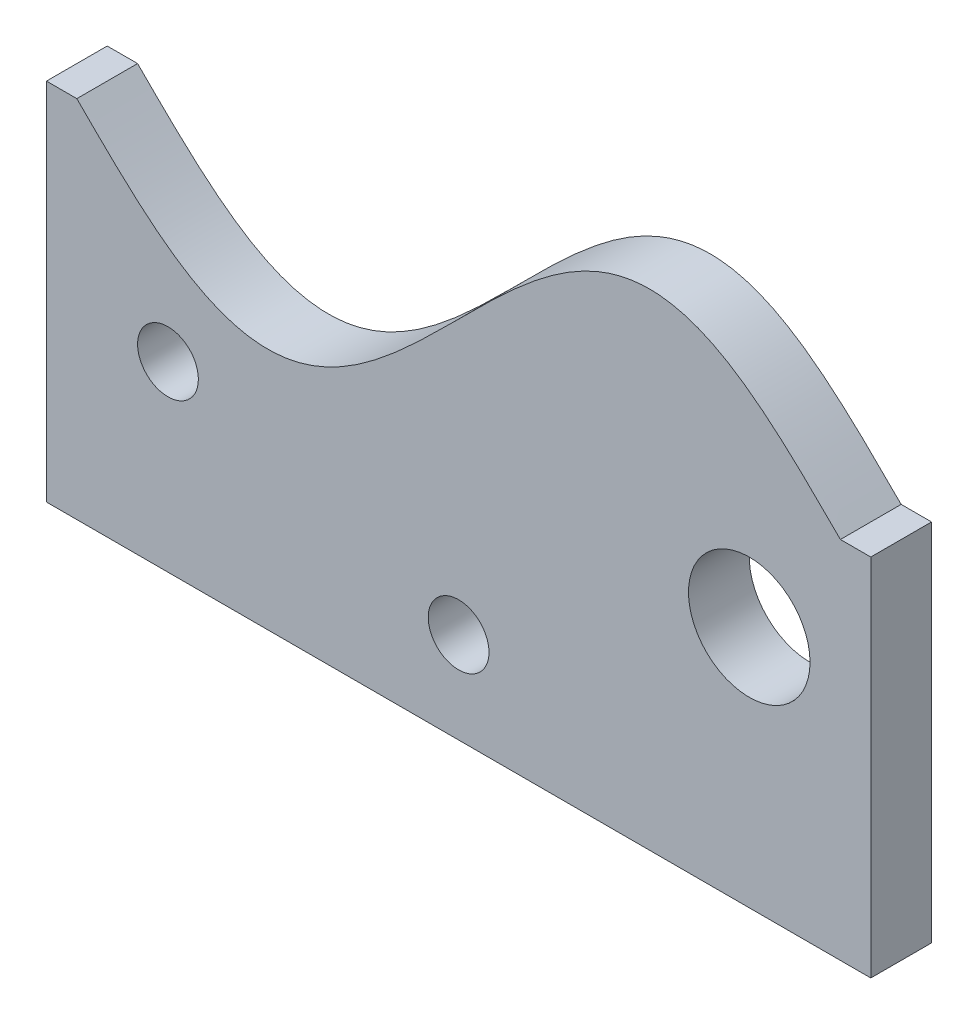
from build123d import *

# Parameters (mm, degrees)
SKETCH1_R           = 6.35
SKETCH1_R_2         = 12.7
BOSS_EXTRUDE1_DEPTH = 6.35


with BuildPart() as part:
    # Sketch1 → Boss-Extrude1 (new body, symmetric)
    with BuildSketch(Plane.XY):
        with BuildLine():
            Line((-79.796453401, 76.2), (-86.146453401, 76.2))
            Line((-86.146453401, 76.2), (-86.146453401, 0))
            Line((-86.146453401, 0), (86.146453401, 0))
            Line((86.146453401, 0), (86.146453401, 76.2))
            Line((86.146453401, 76.2), (79.796453401, 76.2))
            add(Edge.make_bspline(
                [(-79.796453401, 76.2), (-79.189310673, 75.592857272), (-78.419838536, 74.823385314), (-76.839857821, 73.246390226), (-75.851003836, 72.270543834), (-75.034699193, 71.465022368), (-74.31136546, 70.756453846), (-73.576023602, 70.040507975), (-72.649051158, 69.144399927), (-71.532310925, 68.076646001), (-70.219545888, 66.841538959), (-68.485500153, 65.247913117), (-66.807716386, 63.756647213), (-65.185312119, 62.36911953), (-63.618958787, 61.086526883), (-62.34769091, 60.083038976), (-60.733687689, 58.860738712), (-58.999907039, 57.626741231), (-57.13486754, 56.400446885), (-54.689758355, 54.949353195), (-51.661408432, 53.383106741), (-47.681394209, 51.79858192), (-42.756225748, 50.724835978), (-37.483967518, 50.69738214), (-31.963227666, 51.800126692), (-26.958939092, 53.839759909), (-22.374127361, 56.485511101), (-17.5554774, 59.905980771), (-12.89982765, 63.745892876), (-7.93842501, 68.317451576), (-2.627479816, 73.554045081), (2.627480982, 78.845954257), (7.938421068, 84.082550661), (12.899835071, 88.654102914), (17.555465978, 92.49402571), (22.374144001, 95.914479457), (26.958910268, 98.560256445), (31.963269254, 100.599849723), (37.483906393, 101.702652489), (42.756336754, 101.675101345), (47.681204664, 100.601524117), (52.135278168, 98.828187823), (55.851003112, 96.824403503), (58.927126504, 94.848359807), (61.716390424, 92.827512958), (64.26102906, 90.813749271), (66.893187543, 88.584227753), (69.259901401, 86.454968432), (71.335322871, 84.51629968), (73.226893933, 82.7004825), (74.640561752, 81.324965424), (76.227601829, 79.75884352), (77.4656073, 78.52965168), (78.875222889, 77.121230608), (79.492882037, 76.503571364), (79.796453401, 76.2)],
                knots=[0.083220032, 0.083220032, 0.083220032, 0.083220032, 0.083220032, 0.100917711, 0.105342131, 0.10976655, 0.11419097, 0.11861539, 0.123039809, 0.127464229, 0.136313069, 0.145161908, 0.154010747, 0.167923193, 0.174879415, 0.181835638, 0.18879186, 0.195748083, 0.209660528, 0.218392384, 0.22712424, 0.244587953, 0.268184956, 0.29178156, 0.313137051, 0.334492665, 0.364357185, 0.384128158, 0.403899131, 0.435932731, 0.467966332, 0.5, 0.532033668, 0.564067269, 0.596100869, 0.615871842, 0.635642815, 0.665507335, 0.686862949, 0.70821844, 0.731815044, 0.755412047, 0.77287576, 0.790339472, 0.804251917, 0.818164362, 0.832076807, 0.845989253, 0.863686931, 0.872535771, 0.88138461, 0.89023345, 0.899082289, 0.907931129, 0.916779968, 0.916779968, 0.916779968, 0.916779968, 0.916779968], degree=4))
        make_face()
        with Locations((-60.746453401, 38.1)):
            Circle(SKETCH1_R, mode=Mode.SUBTRACT)
        with Locations((0, 19.05)):
            Circle(SKETCH1_R, mode=Mode.SUBTRACT)
        with Locations((60.746453401, 50.8)):
            Circle(SKETCH1_R_2, mode=Mode.SUBTRACT)
    extrude(amount=BOSS_EXTRUDE1_DEPTH, both=True)


solid = part.part
